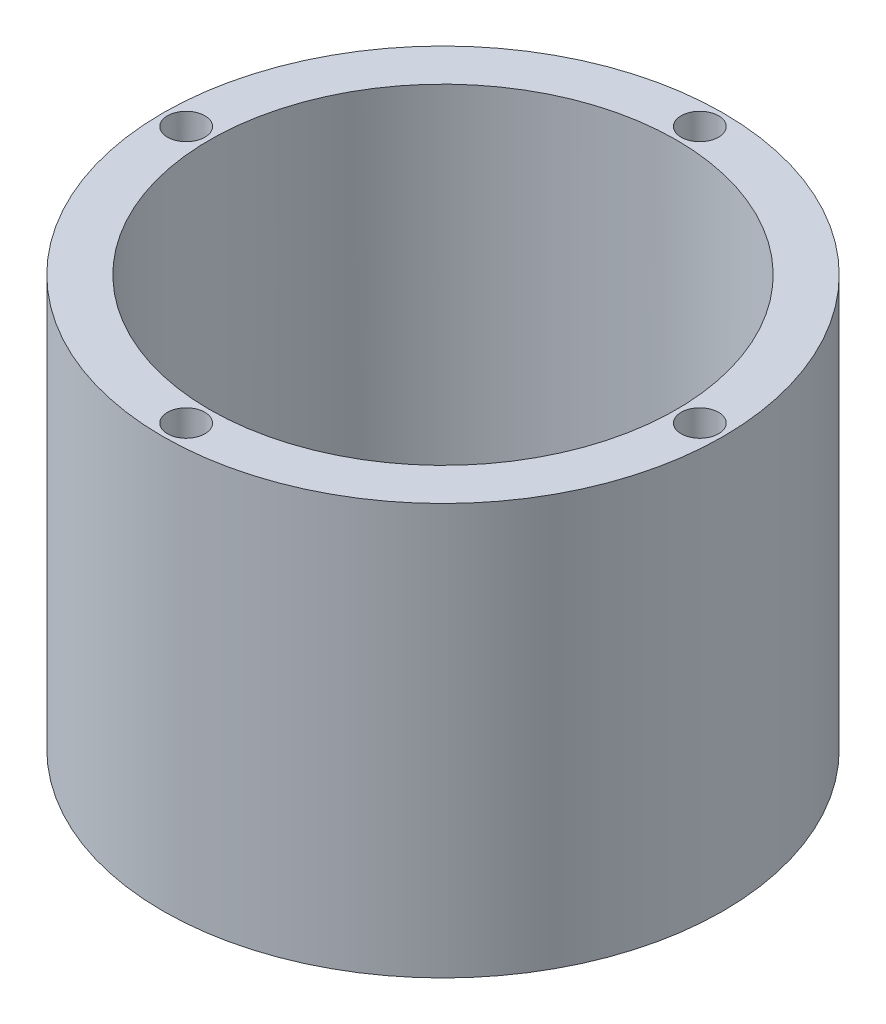
from build123d import *

# Parameters (mm, degrees)
CROQUIS2_R              = 30
SALIENTE_EXTRUIR1_DEPTH = 4
CORTAR_EXTRUIR1_DEPTH   = 1
CROQUIS3_R              = 3.7
CORTAR_EXTRUIR2_DEPTH   = 3
CROQUIS5_W              = 5
CROQUIS5_H              = 80
CROQUIS6_R              = 2
CORTAR_EXTRUIR3_DEPTH   = 46
CROQUIS7_W              = 60
CROQUIS7_H              = 40
CORTAR_EXTRUIR4_DEPTH   = 30


with BuildPart() as part:
    # Croquis2 → Saliente-Extruir1 (new body)
    with BuildSketch(Plane(origin=(0, 0, 0), x_dir=(1, 0, 0), z_dir=(0, 1, 0))):
        Circle(CROQUIS2_R)
    extrude(amount=-SALIENTE_EXTRUIR1_DEPTH)

    # Croquis1 → Cortar-Extruir1 (cut)
    with BuildSketch(Plane(origin=(0, 0, 0), x_dir=(1, 0, 0), z_dir=(0, 1, 0))):
        with BuildLine():
            Line((18, -2.1), (18, 2.1))
            Line((18, 2.1), (1.92939966, 3.178620376))
            ThreePointArc((1.92939966, 3.178620376), (0, 3.718361271), (-1.92939966, 3.178620376))
            Line((-1.92939966, 3.178620376), (-18, 2.1))
            Line((-18, 2.1), (-18, -2.1))
            Line((-18, -2.1), (-1.92939966, -3.178620376))
            ThreePointArc((-1.92939966, -3.178620376), (0, -3.718361271), (1.92939966, -3.178620376))
            Line((1.92939966, -3.178620376), (18, -2.1))
        make_face()
    extrude(amount=-CORTAR_EXTRUIR1_DEPTH, mode=Mode.SUBTRACT)

    # Croquis3 → Cortar-Extruir2 (cut)
    with BuildSketch(Plane(origin=(0, -1, 0), x_dir=(1, 0, 0), z_dir=(0, 1, 0))):
        Circle(CROQUIS3_R)
    extrude(amount=-CORTAR_EXTRUIR2_DEPTH, mode=Mode.SUBTRACT)

    # Croquis5 → Revolución1 (revolve)
    with BuildSketch(Plane.XY):
        with Locations((27.5, 40)):
            Rectangle(CROQUIS5_W, CROQUIS5_H)
    revolve(axis=Axis((0, 80, 0), (0, -1, 0)))

    # Croquis6 → Cortar-Extruir3 (cut)
    with BuildSketch(Plane(origin=(0, 80, 0), x_dir=(1, 0, 0), z_dir=(0, 1, 0))):
        with Locations((27.5, 0)):
            Circle(CROQUIS6_R)
        with Locations((0, -27.5)):
            Circle(CROQUIS6_R)
        with Locations((-27.5, 0)):
            Circle(CROQUIS6_R)
        with Locations((0, 27.5)):
            Circle(CROQUIS6_R)
    extrude(amount=-CORTAR_EXTRUIR3_DEPTH, mode=Mode.SUBTRACT)

    # Croquis7 → Cortar-Extruir4 (cut)
    with BuildSketch(Plane.XY):
        with Locations((0, 60)):
            Rectangle(CROQUIS7_W, CROQUIS7_H)
    cortar_extruir4 = extrude(amount=-CORTAR_EXTRUIR4_DEPTH, mode=Mode.SUBTRACT)

    # Simetría1: Cortar-Extruir4 across plane
    add(cortar_extruir4.mirror(Plane.XY), mode=Mode.SUBTRACT)


solid = part.part
